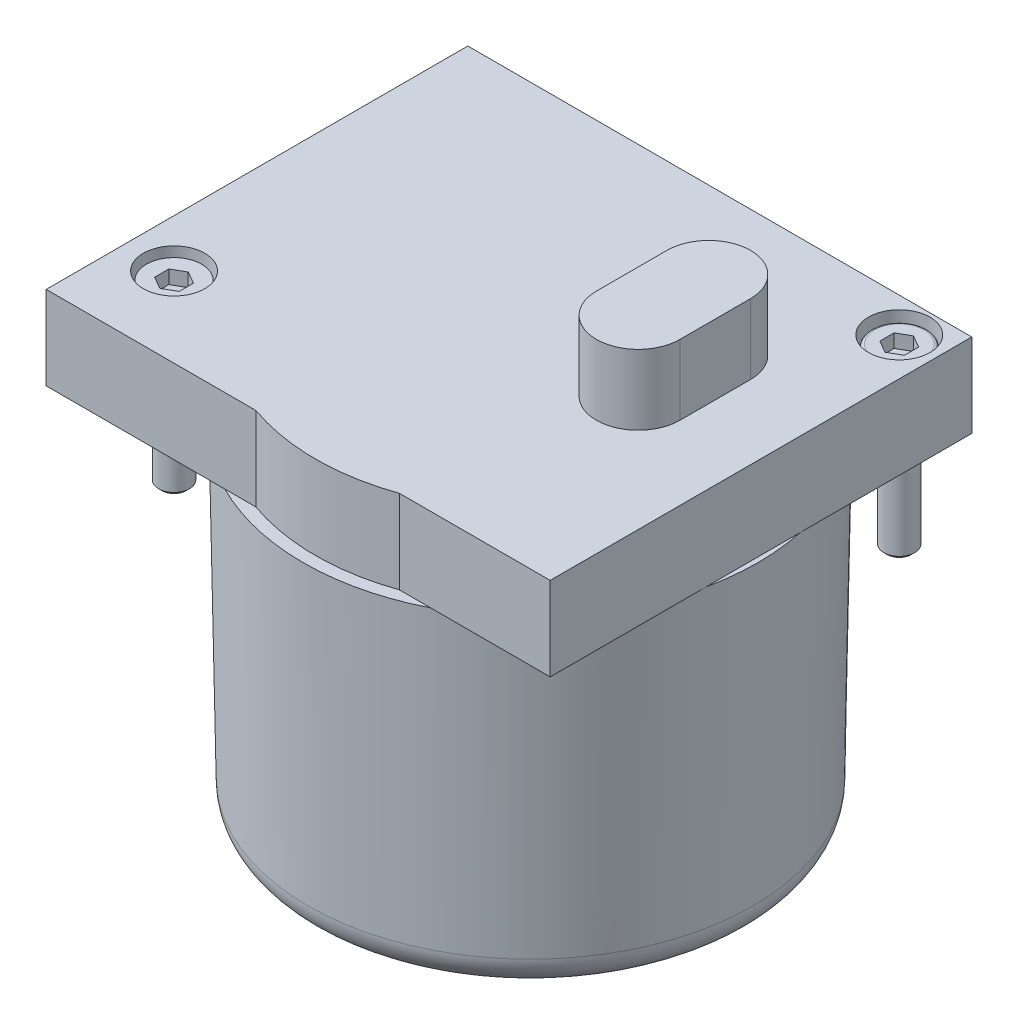
from build123d import *

# Parameters (mm, degrees)
BOSS_EXTRUDE1_DEPTH = 6.8
CUT_EXTRUDE1_DEPTH  = 15
CUT_EXTRUDE2_DEPTH  = 8
BOSS_EXTRUDE2_DEPTH = 5.7
CUT_EXTRUDE3_DEPTH  = 1.1
CUT_EXTRUDE4_DEPTH  = 1.1


with BuildPart() as part:
    # Sketch1 → Revolve1 (revolve)
    with BuildSketch(Plane.XY):
        Polygon((2.4, 0), (19.9, 0), (19.9, -0.858578644), (19.758578644, -1), (18.4, -1), (18.4, -2.5), (19.758578644, -2.5), (19.9, -2.641421356), (19.9, -21), (2.4, -21), align=None)
    revolve(axis=Axis((2.4, -21, 0), (0, 1, 0)))

    # Sketch2 → Boss-Extrude1 (add)
    with BuildSketch(Plane(origin=(0, 0, 0), x_dir=(1, 0, 0), z_dir=(0, 1, 0))):
        with BuildLine():
            Line((-20.5, 17.8), (-20.5, -16.5))
            Line((-20.5, -16.5), (-3.430951895, -16.5))
            ThreePointArc((-3.430951895, -16.5), (2.4, -17.5), (8.230951895, -16.5))
            Line((8.230951895, -16.5), (20.5, -16.5))
            Line((20.5, -16.5), (20.5, 17.8))
            Line((20.5, 17.8), (-20.5, 17.8))
        make_face()
    extrude(amount=BOSS_EXTRUDE1_DEPTH)

    # Sketch3 → Cut-Extrude1 (cut)
    with BuildSketch(Plane(origin=(0, -21, 0), x_dir=(-1, 0, 0), z_dir=(0, -1, 0))):
        with BuildLine():
            Line((0.6, 18.103107468), (0.6, 14.645903864))
            ThreePointArc((0.6, 14.645903864), (-2.4, 14.95), (-5.4, 14.645903864))
            Line((-5.4, 14.645903864), (-5.4, 18.103107468))
            ThreePointArc((-5.4, 18.103107468), (-9.241062733, 17.027106645), (-12.758856756, 15.146504108))
            ThreePointArc((-12.758856756, 15.146504108), (-12.971246379, 10.571246379), (-17.546504108, 10.358856756))
            ThreePointArc((-17.546504108, 10.358856756), (-19.427106645, 6.841062733), (-20.503107468, 3))
            Line((-20.503107468, 3), (-17.045903864, 3))
            ThreePointArc((-17.045903864, 3), (-17.35, 0), (-17.045903864, -3))
            Line((-17.045903864, -3), (-20.503107468, -3))
            ThreePointArc((-20.503107468, -3), (-19.427106645, -6.841062733), (-17.546504108, -10.358856756))
            ThreePointArc((-17.546504108, -10.358856756), (-12.971246379, -10.571246379), (-12.758856756, -15.146504108))
            ThreePointArc((-12.758856756, -15.146504108), (-9.241062733, -17.027106645), (-5.4, -18.103107468))
            Line((-5.4, -18.103107468), (-5.4, -14.645903864))
            ThreePointArc((-5.4, -14.645903864), (-2.4, -14.95), (0.6, -14.645903864))
            Line((0.6, -14.645903864), (0.6, -18.103107468))
            ThreePointArc((0.6, -18.103107468), (4.441062733, -17.027106645), (7.958856756, -15.146504108))
            ThreePointArc((7.958856756, -15.146504108), (8.171246379, -10.571246379), (12.746504108, -10.358856756))
            ThreePointArc((12.746504108, -10.358856756), (14.627106645, -6.841062733), (15.703107468, -3))
            Line((15.703107468, -3), (12.245903864, -3))
            ThreePointArc((12.245903864, -3), (12.55, 0), (12.245903864, 3))
            Line((12.245903864, 3), (15.703107468, 3))
            ThreePointArc((15.703107468, 3), (14.627106645, 6.841062733), (12.746504108, 10.358856756))
            ThreePointArc((12.746504108, 10.358856756), (8.171246379, 10.571246379), (7.958856756, 15.146504108))
            ThreePointArc((7.958856756, 15.146504108), (4.441062733, 17.027106645), (0.6, 18.103107468))
        make_face()
    extrude(amount=-CUT_EXTRUDE1_DEPTH, mode=Mode.SUBTRACT)

    # Sketch4 → Cut-Extrude2 (cut)
    with BuildSketch(Plane(origin=(0, -21, 0), x_dir=(-1, 0, 0), z_dir=(0, -1, 0))):
        Polygon((18.813203436, -14.142135624), (4.671067812, 0), (18.813203436, 14.142135624), (11.742135624, 21.213203436), (-2.4, 7.071067812), (-16.542135624, 21.213203436), (-23.613203436, 14.142135624), (-9.471067812, 0), (-23.613203436, -14.142135624), (-16.542135624, -21.213203436), (-2.4, -7.071067812), (11.742135624, -21.213203436), align=None)
    extrude(amount=-CUT_EXTRUDE2_DEPTH, mode=Mode.SUBTRACT)

    # Sketch5 → Boss-Extrude2 (add)
    with BuildSketch(Plane(origin=(0, 6.8, 0), x_dir=(1, 0, 0), z_dir=(0, 1, 0))):
        with BuildLine():
            Line((14.5, 0.06), (14.5, 5.8))
            ThreePointArc((14.5, 5.8), (11.1, 9.2), (7.7, 5.8))
            Line((7.7, 5.8), (7.7, 0.06))
            ThreePointArc((7.7, 0.06), (11.1, -3.34), (14.5, 0.06))
        make_face()
    extrude(amount=BOSS_EXTRUDE2_DEPTH)

    # Sketch6 → Cut-Revolve1 (revolve, cut)
    with BuildSketch(Plane.XY.offset(-15)):
        Polygon((17.4, 6.8), (19.9, 6.8), (19.9, 3.8), (18.65, 3.8), (18.65, -0.2), (17.4, -0.2), align=None)
    revolve(axis=Axis((17.4, -0.2, -15), (0, 1, 0)), mode=Mode.SUBTRACT)

    # Sketch7 → Revolve2 (revolve)
    with BuildSketch(Plane.XY.offset(-15)):
        with BuildLine():
            Line((17.4, 6.15), (19.4, 6.15))
            ThreePointArc((19.4, 6.15), (19.576776695, 6.076776695), (19.65, 5.9))
            Line((19.65, 5.9), (19.65, 3.8))
            Line((19.65, 3.8), (18.65, 3.8))
            Line((18.65, 3.8), (18.65, -7.924))
            Line((18.65, -7.924), (18.374, -8.2))
            Line((18.374, -8.2), (17.4, -8.2))
            Line((17.4, -8.2), (17.4, 6.15))
        make_face()
    revolve(axis=Axis((17.4, -8.2, -15), (0, 1, 0)))

    # Sketch8 → Cut-Extrude3 (cut)
    with BuildSketch(Plane(origin=(0, 6.15, 0), x_dir=(1, 0, 0), z_dir=(0, 1, 0))):
        Polygon((16.4, 14.422649731), (17.4, 13.845299462), (18.4, 14.422649731), (18.4, 15.577350269), (17.4, 16.154700538), (16.4, 15.577350269), align=None)
    extrude(amount=-CUT_EXTRUDE3_DEPTH, mode=Mode.SUBTRACT)

    # Sketch9 → Cut-Revolve2 (revolve, cut)
    with BuildSketch(Plane.XY.offset(10)):
        Polygon((-16.6, 6.8), (-14.1, 6.8), (-14.1, 3.8), (-15.35, 3.8), (-15.35, -0.2), (-16.6, -0.2), align=None)
    revolve(axis=Axis((-16.6, -0.2, 10), (0, 1, 0)), mode=Mode.SUBTRACT)

    # Sketch10 → Revolve3 (revolve)
    with BuildSketch(Plane.XY.offset(10)):
        Polygon((-16.6, 6.15), (-14.35, 6.15), (-14.35, 3.8), (-15.35, 3.8), (-15.35, -7.924), (-15.626, -8.2), (-16.6, -8.2), align=None)
    revolve(axis=Axis((-16.6, -8.2, 10), (0, 1, 0)))

    # Sketch11 → Cut-Extrude4 (cut)
    with BuildSketch(Plane(origin=(0, 6.15, 0), x_dir=(1, 0, 0), z_dir=(0, 1, 0))):
        Polygon((-17.6, -10.577350269), (-16.6, -11.154700538), (-15.6, -10.577350269), (-15.6, -9.422649731), (-16.6, -8.845299462), (-17.6, -9.422649731), align=None)
    extrude(amount=-CUT_EXTRUDE4_DEPTH, mode=Mode.SUBTRACT)

    # Sketch12 → Revolve4 (revolve)
    with BuildSketch(Plane.XY):
        with BuildLine():
            Line((2.6, -26), (2.6, -27))
            Line((2.6, -27), (17.846723092, -27))
            ThreePointArc((17.846723092, -27), (19.696678603, -26.242917592), (20.485096336, -24.406097884))
            Line((20.485096336, -24.406097884), (20.9, 0))
            Line((20.9, 0), (19.89985551, 0))
            Line((19.89985551, 0), (19.485240806, -24.389100276))
            ThreePointArc((19.485240806, -24.389100276), (18.995607117, -25.529826594), (17.846723028, -26))
            Line((17.846723028, -26), (2.6, -26))
        make_face()
    revolve(axis=Axis((2.4, -27, 0), (0, 1, 0)))


solid = part.part
